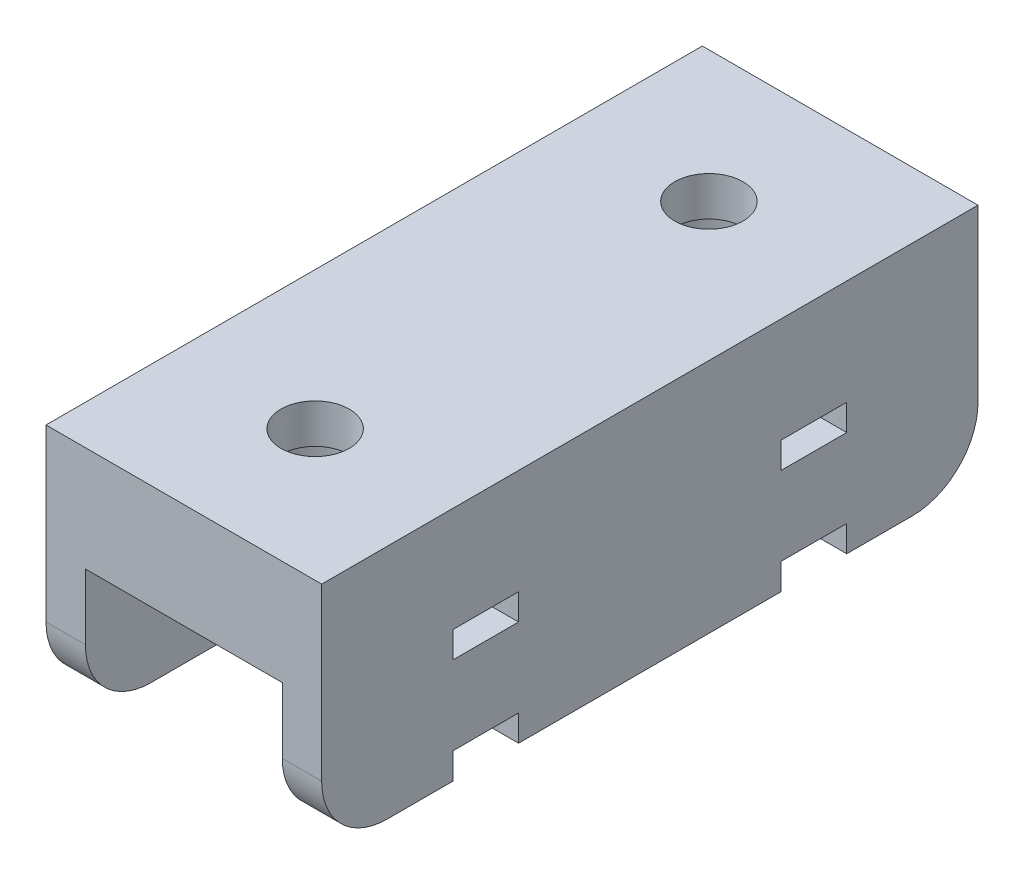
from build123d import *

# Parameters (mm, degrees)
SKETCH1_W           = 21
SKETCH1_H           = 50
SKETCH1_R           = 2.6
BOSS_EXTRUDE1_DEPTH = 8
SKETCH2_R           = 4.5
CUT_EXTRUDE1_DEPTH  = 5
SKETCH3_W           = 3
SKETCH3_H           = 10
BOSS_EXTRUDE2_DEPTH = 50
SKETCH4_W           = 2
SKETCH4_H           = 5
CUT_EXTRUDE2_DEPTH  = 22
FILLET1_R           = 5


with BuildPart() as part:
    # Sketch1 → Boss-Extrude1 (new body)
    with BuildSketch(Plane(origin=(0, 0, 0), x_dir=(1, 0, 0), z_dir=(0, 1, 0))):
        Rectangle(SKETCH1_W, SKETCH1_H)
        with Locations((0, -15)):
            Circle(SKETCH1_R, mode=Mode.SUBTRACT)
        with Locations((0, 15)):
            Circle(SKETCH1_R, mode=Mode.SUBTRACT)
    extrude(amount=BOSS_EXTRUDE1_DEPTH)

    # Sketch2 → Cut-Extrude1 (cut)
    with BuildSketch(Plane.XZ):
        with Locations((0, 15)):
            Circle(SKETCH2_R)
        with Locations((0, -15)):
            Circle(SKETCH2_R)
    extrude(amount=-CUT_EXTRUDE1_DEPTH, mode=Mode.SUBTRACT)

    # Sketch3 → Boss-Extrude2 (add)
    with BuildSketch(Plane.XY.offset(25)):
        with Locations((-9, -5)):
            Rectangle(SKETCH3_W, SKETCH3_H)
        with Locations((9, -5)):
            Rectangle(SKETCH3_W, SKETCH3_H)
    extrude(amount=-BOSS_EXTRUDE2_DEPTH)

    # Sketch4 → Cut-Extrude2 (cut, through all)
    with BuildSketch(Plane(origin=(10.5, 13.5, 0), x_dir=(0, -1, 0), z_dir=(1, 0, 0))):
        with Locations((14.5, -12.5)):
            Rectangle(SKETCH4_W, SKETCH4_H)
        with Locations((22.5, -12.5)):
            Rectangle(SKETCH4_W, SKETCH4_H)
        with Locations((22.5, 12.5)):
            Rectangle(SKETCH4_W, SKETCH4_H)
        with Locations((14.5, 12.5)):
            Rectangle(SKETCH4_W, SKETCH4_H)
    extrude(amount=-CUT_EXTRUDE2_DEPTH, mode=Mode.SUBTRACT)

    # Fillet1
    fillet1_edges = [part.edges().sort_by_distance(p)[0] for p in [
        (-9, -10, -25),
        (-9, -10, 25),
        (9, -10, 25),
        (9, -10, -25),
    ]]
    fillet(fillet1_edges, radius=FILLET1_R)


solid = part.part
